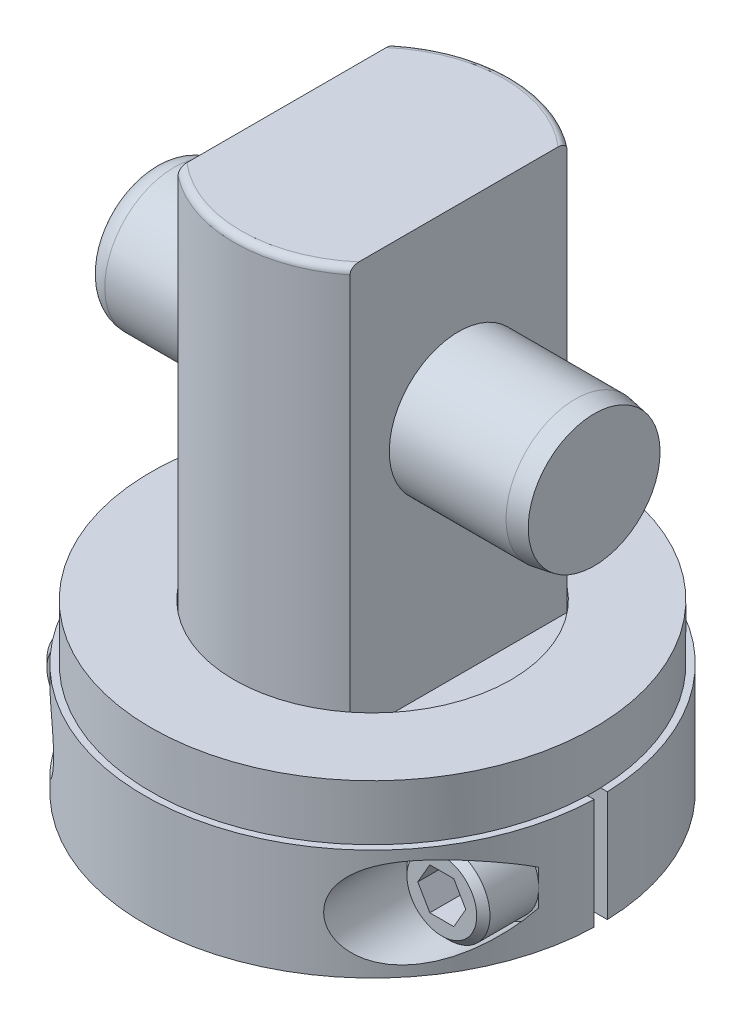
from build123d import *

# Parameters (mm, degrees)
FILLET1_R                  = 0.7874
SKETCH2_W                  = 6.0198
SKETCH2_H                  = 46.736
CUT_EXTRUDE1_DEPTH         = 16.875
CUT_EXTRUDE1_DEPTH_BACK    = 16.875
SKETCH3_R                  = 7.9375
SKETCH3_R_2                = 7.0866
CUT_EXTRUDE2_DEPTH         = 2.54
CHAMFER1_SIZE              = 0.762
SKETCH4_R                  = 7.94004
EXTRUDE1_DEPTH             = 25.4
CHAMFER2_SIZE              = 0.381
CHAMFER2_SIZE2             = 2.160758373
FILLET2_R                  = 2.6416
EXTRUDE2_DEPTH             = 6.35
EXTRUDE2_DEPTH_BACK        = 6.35
CUT_EXTRUDE3_START         = 5.588
SKETCH6_R                  = 5.1562
CUT_EXTRUDE3_DEPTH         = 20.812
SKETCH7_R                  = 4.7625
EXTRUDE3_DEPTH             = 6.35
CHAMFER3_SIZE              = 0.762
CUT_EXTRUDE4_DEPTH         = 4.7625
EXTRUDE4_REACH             = 28.162
SKETCH10_R                 = 3.175
EXTRUDE4_DIRECTION_2_REACH = 28.162
SKETCH11_R                 = 25.4
SKETCH11_R_2               = 15.875
EXTRUDE5_DEPTH             = 6.35


with BuildPart() as part:
    # Sketch1 → Revolve1 (revolve)
    with BuildSketch(Plane(origin=(0, 0, 0), x_dir=(0, 0, -1), z_dir=(1, 0, 0))):
        Polygon((0, 56.896), (15.875, 56.896), (15.875, 0), (7.9375, 0), (7.9375, -16.129), (0, -16.129), align=None)
    revolve(axis=Axis((0, -15.35938, 0), (0, 1, 0)))

    # Fillet1
    fillet1_edges = [part.edges().sort_by_distance(p)[0] for p in [
        (0, 56.896, 15.875),
    ]]
    fillet(fillet1_edges, radius=FILLET1_R)

    # Sketch2 → Cut-Extrude1 (cut, two sides)
    with BuildSketch(Plane.XY) as cut_extrude1_sk:
        with Locations((12.8651, 33.528)):
            Rectangle(SKETCH2_W, SKETCH2_H)
        with Locations((-12.8651, 33.528)):
            Rectangle(SKETCH2_W, SKETCH2_H)
    extrude(amount=CUT_EXTRUDE1_DEPTH, mode=Mode.SUBTRACT)
    extrude(cut_extrude1_sk.sketch, amount=-CUT_EXTRUDE1_DEPTH_BACK, mode=Mode.SUBTRACT)

    # Sketch3 → Cut-Extrude2 (cut)
    with BuildSketch(Plane.XZ):
        with Locations(Location((0, 0, 0), (0, 0, 270))):  # turned: the seam where the file's is
            Circle(SKETCH3_R)
        with Locations(Location((0, 0, 0), (0, 0, 270))):  # turned: the seam where the file's is
            Circle(SKETCH3_R_2, mode=Mode.SUBTRACT)
    extrude(amount=CUT_EXTRUDE2_DEPTH, mode=Mode.SUBTRACT)

    # Chamfer1
    chamfer1_edges = [part.edges().sort_by_distance(p)[0] for p in [
        (0, -16.129, 7.9375),
    ]]
    chamfer(chamfer1_edges, length=CHAMFER1_SIZE)

    # Sketch4 → Extrude1 (add, symmetric)
    with BuildSketch(Plane(origin=(0, 0, 0), x_dir=(0, 0, -1), z_dir=(1, 0, 0))):
        with Locations(Location((0, 36.322, 0), (0, 0, 90))):  # turned: the seam where the file's is
            Circle(SKETCH4_R)
    extrude(amount=EXTRUDE1_DEPTH, both=True)

    # Chamfer2
    chamfer2_edges = [part.edges().sort_by_distance(p)[0] for p in [
        (25.4, 28.38196, 0),
    ]]
    chamfer2_side = [part.faces().sort_by_distance(p)[0] for p in [
        (25.4, 36.322, 0),
    ]]
    chamfer(chamfer2_edges, length=CHAMFER2_SIZE, length2=CHAMFER2_SIZE2, reference=chamfer2_side[0])

    # Fillet2
    fillet2_edges = [part.edges().sort_by_distance(p)[0] for p in [
        (-25.4, 28.38196, 0),
    ]]
    fillet(fillet2_edges, radius=FILLET2_R)

    # Sketch5 → Extrude2 (add, two sides)
    with BuildSketch(Plane(origin=(0, 0, 0), x_dir=(1, 0, 0), z_dir=(0, 1, 0))) as extrude2_sk:
        with BuildLine():
            Line((15.856701454, 0.762), (26.150900558, 0.762))
            ThreePointArc((26.150900558, 0.762), (0, 26.162), (-26.150900558, 0.762))
            Line((-26.150900558, 0.762), (-15.856701454, 0.762))
            ThreePointArc((-15.856701454, 0.762), (0, 15.875), (15.856701454, 0.762))
        make_face()
        with BuildLine():
            Line((15.856701454, -0.762), (26.150900558, -0.762))
            ThreePointArc((26.150900558, -0.762), (0, -26.162), (-26.150900558, -0.762))
            Line((-26.150900558, -0.762), (-15.856701454, -0.762))
            ThreePointArc((-15.856701454, -0.762), (0, -15.875), (15.856701454, -0.762))
        make_face()
    extrude(amount=EXTRUDE2_DEPTH)
    extrude(extrude2_sk.sketch, amount=-EXTRUDE2_DEPTH_BACK)

    # Sketch6 → Cut-Extrude3 (cut, through all)
    with BuildSketch(Plane.XY.offset(0.762).offset(CUT_EXTRUDE3_START)):
        with Locations((20.6375, 0)):
            Circle(SKETCH6_R)
        with Locations((-20.6375, 0)):
            Circle(SKETCH6_R)
    extrude(amount=CUT_EXTRUDE3_DEPTH, mode=Mode.SUBTRACT)

    # Sketch7 → Extrude3 (add)
    with BuildSketch(Plane.XY.offset(6.35)):
        with Locations(Location((20.6375, 0, 0), (0, 0, 5.295701499))):  # turned: the seam where the file's is
            Circle(SKETCH7_R)
        with Locations(Location((-20.6375, 0, 0), (0, 0, 185.295701499))):  # turned: the seam where the file's is
            Circle(SKETCH7_R)
    extrude(amount=EXTRUDE3_DEPTH)

    # Chamfer3
    chamfer3_edges = [part.edges().sort_by_distance(p)[0] for p in [
        (15.895328135, -0.439559152, 12.7),
        (-15.895328135, 0.439559152, 12.7),
    ]]
    chamfer(chamfer3_edges, length=CHAMFER3_SIZE)

    # Sketch8 → Cut-Extrude4 (cut)
    with BuildSketch(Plane.XY.offset(12.7)):
        Polygon((22.012315329, 2.38125), (23.387130657, 0), (22.012315329, -2.38125), (19.262684671, -2.38125), (17.887869343, 0), (19.262684671, 2.38125), align=None)
        Polygon((-23.387130657, 0), (-22.012315329, -2.38125), (-19.262684671, -2.38125), (-17.887869343, 0), (-19.262684671, 2.38125), (-22.012315329, 2.38125), align=None)
    extrude(amount=-CUT_EXTRUDE4_DEPTH, mode=Mode.SUBTRACT)

    # Sketch10 → Extrude4 (add, up to next)
    with BuildSketch(Plane.XY, mode=Mode.PRIVATE) as extrude4_sk1:
        with Locations((20.6375, 0)):
            Circle(SKETCH10_R)
    extrude4_tool1 = extrude(extrude4_sk1.sketch, amount=EXTRUDE4_REACH, mode=Mode.PRIVATE) - part.part
    add(extrude4_tool1.solids().sort_by_distance((20.6375, 0, 0))[0])
    # Sketch10 → Extrude4 (add, up to next)
    with BuildSketch(Plane.XY, mode=Mode.PRIVATE) as extrude4_sk2:
        with Locations((-20.6375, 0)):
            Circle(SKETCH10_R)
    extrude4_tool2 = extrude(extrude4_sk2.sketch, amount=EXTRUDE4_REACH, mode=Mode.PRIVATE) - part.part
    add(extrude4_tool2.solids().sort_by_distance((-20.6375, 0, 0))[0])

    # Sketch10 → Extrude4 direction 2 (add, up to next)
    with BuildSketch(Plane.XY, mode=Mode.PRIVATE) as extrude4_direction_2_sk1:
        with Locations((20.6375, 0)):
            Circle(SKETCH10_R)
    extrude4_direction_2_tool1 = extrude(extrude4_direction_2_sk1.sketch, amount=-EXTRUDE4_DIRECTION_2_REACH, mode=Mode.PRIVATE) - part.part
    add(extrude4_direction_2_tool1.solids().sort_by_distance((20.6375, 0, 0))[0])
    # Sketch10 → Extrude4 direction 2 (add, up to next)
    with BuildSketch(Plane.XY, mode=Mode.PRIVATE) as extrude4_direction_2_sk2:
        with Locations((-20.6375, 0)):
            Circle(SKETCH10_R)
    extrude4_direction_2_tool2 = extrude(extrude4_direction_2_sk2.sketch, amount=-EXTRUDE4_DIRECTION_2_REACH, mode=Mode.PRIVATE) - part.part
    add(extrude4_direction_2_tool2.solids().sort_by_distance((-20.6375, 0, 0))[0])

    # Sketch11 → Extrude5 (add)
    with BuildSketch(Plane(origin=(0, 6.35, 0), x_dir=(-1, 0, 0), z_dir=(0, 1, 0))):
        with Locations(Location((0, 0, 0), (0, 0, 181.719131321))):  # turned: the seam where the file's is
            Circle(SKETCH11_R)
        Circle(SKETCH11_R_2, mode=Mode.SUBTRACT)
    extrude(amount=EXTRUDE5_DEPTH)


solid = part.part
